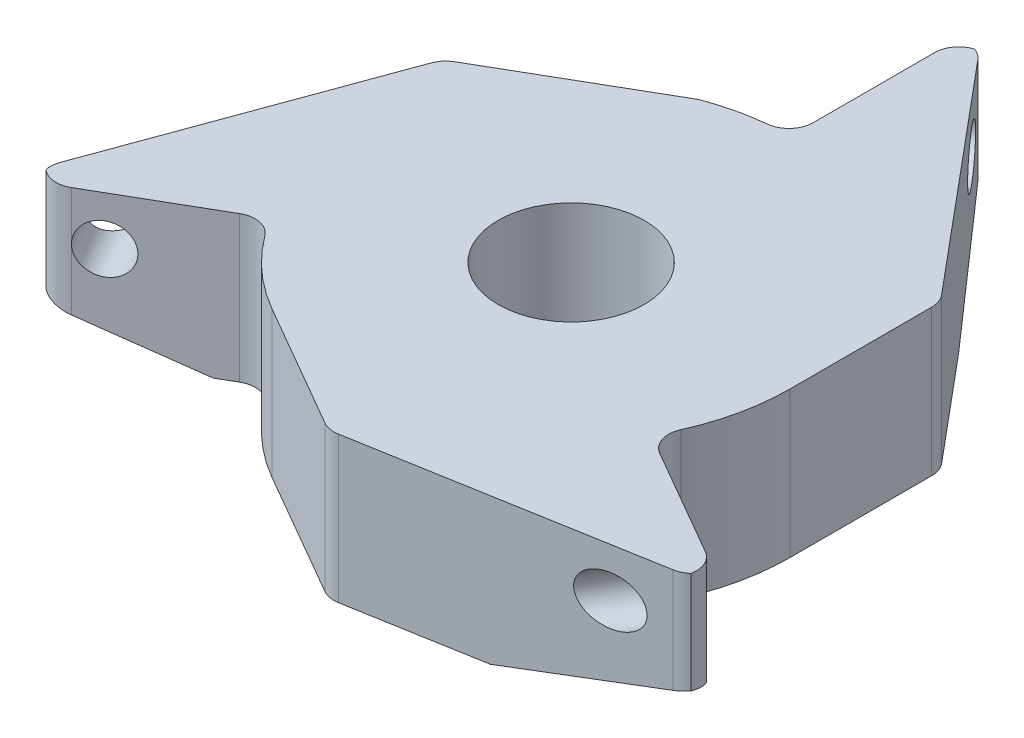
from build123d import *

# Parameters (mm, degrees)
SKETCH1_R           = 3
BOSS_EXTRUDE1_DEPTH = 6
SKETCH2_R           = 1
CUT_EXTRUDE1_DEPTH  = 21.931256894
CIRPATTERN1_COUNT   = 3


with BuildPart() as part:
    # Sketch1 → Boss-Extrude1 (new body)
    with BuildSketch(Plane(origin=(0, 0, 0), x_dir=(1, 0, 0), z_dir=(0, 1, 0))):
        with BuildLine():
            Line((0, 9.949874371), (0, 14.931500001))
            ThreePointArc((0, 14.931500001), (0.189758469, 15.51759612), (0.687017323, 15.881258835))
            ThreePointArc((0.687017323, 15.881258835), (0.935555017, 15.758962914), (1.141008782, 15.573178015))
            Line((1.141008782, 15.573178015), (8.766974136, 6.458142033))
            ThreePointArc((8.766974136, 6.458142033), (8.939939928, 6.157803926), (9, 5.816464019))
            Line((9, 5.816464019), (9, 0))
            ThreePointArc((9, 0), (8.79904643, -1.891238198), (8.205159573, -3.698020604))
            ThreePointArc((8.205159573, -3.698020604), (8.165086544, -4.415763214), (8.61684397, -4.974937186))
            Line((8.61684397, -4.974937186), (13.049703796, -7.53425))
            ThreePointArc((13.049703796, -7.53425), (13.46239869, -7.991633714), (13.528710413, -8.604103871))
            ThreePointArc((13.528710413, -8.604103871), (13.298530191, -8.758195867), (13.034908867, -8.843231598))
            Line((13.034908867, -8.843231598), (1.328073473, -10.889993332))
            ThreePointArc((1.328073473, -10.889993332), (0.981490146, -10.889617048), (0.655851079, -10.770960643))
            Line((0.655851079, -10.770960643), (-4.5, -7.794228634))
            ThreePointArc((-4.5, -7.794228634), (-5.997456612, -6.71047794), (-7.241917412, -5.34365345))
            ThreePointArc((-7.241917412, -5.34365345), (-7.842273701, -4.958484648), (-8.546574902, -5.071367319))
            Line((-8.546574902, -5.071367319), (-12.931058317, -7.602749999))
            ThreePointArc((-12.931058317, -7.602749999), (-13.53351168, -7.731462404), (-14.097082257, -7.482654962))
            ThreePointArc((-14.097082257, -7.482654962), (-14.115439729, -7.206267044), (-14.05727217, -6.935446415))
            Line((-14.05727217, -6.935446415), (-9.97640213, 4.226351301))
            ThreePointArc((-9.97640213, 4.226351301), (-9.802784595, 4.526313125), (-9.537205601, 4.748996626))
            Line((-9.537205601, 4.748996626), (-3.17926678, 8.419754316))
            ThreePointArc((-3.17926678, 8.419754316), (-2.057108673, 8.761752331), (-0.9, 8.954886934))
            ThreePointArc((-0.9, 8.954886934), (-0.258380151, 9.279053978), (0, 9.949874371))
        make_face()
        Circle(SKETCH1_R, mode=Mode.SUBTRACT)
    extrude(amount=BOSS_EXTRUDE1_DEPTH)

    # Sketch2 → Cut-Extrude1 (cut, through all)
    with BuildSketch(Plane(origin=(0.059322739, 0, 0.102749999), x_dir=(0.866025404, 0, -0.5), z_dir=(0.5, 0, 0.866025404))):
        with Locations((-14, 4)):
            Circle(SKETCH2_R)
        Polygon((-16.333715653, 1.923120107), (-10.056863633, -0.231620139), (-16.333715653, -0.231620139), align=None)
    cut_extrude1 = extrude(amount=-CUT_EXTRUDE1_DEPTH, mode=Mode.SUBTRACT)

    # CirPattern1: Cut-Extrude1 ×3 about axis
    cirpattern1_axis = Axis((0, 0, 0), (0, 1, 0))
    for i in range(1, CIRPATTERN1_COUNT):
        add(cut_extrude1.rotate(cirpattern1_axis, i * 360 / CIRPATTERN1_COUNT), mode=Mode.SUBTRACT)


solid = part.part
